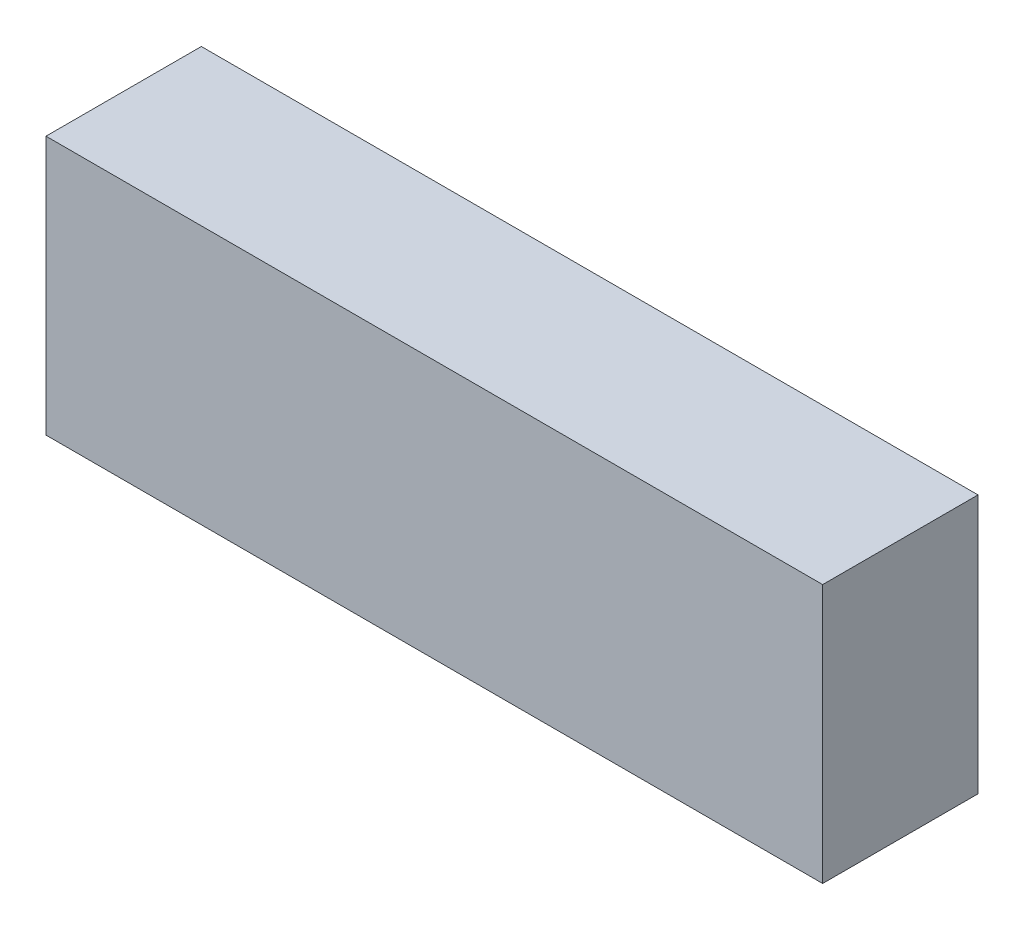
from build123d import *

# Parameters (mm, degrees)
SKETCH1_W           = 150
SKETCH1_H           = 30
BOSS_EXTRUDE2_DEPTH = 50


with BuildPart() as part:
    # Sketch1 → Boss-Extrude2 (new body)
    with BuildSketch(Plane(origin=(0, 0, 0), x_dir=(1, 0, 0), z_dir=(0, 1, 0))):
        with Locations((0, 13.235294118)):
            Rectangle(SKETCH1_W, SKETCH1_H)
    extrude(amount=BOSS_EXTRUDE2_DEPTH)


solid = part.part
